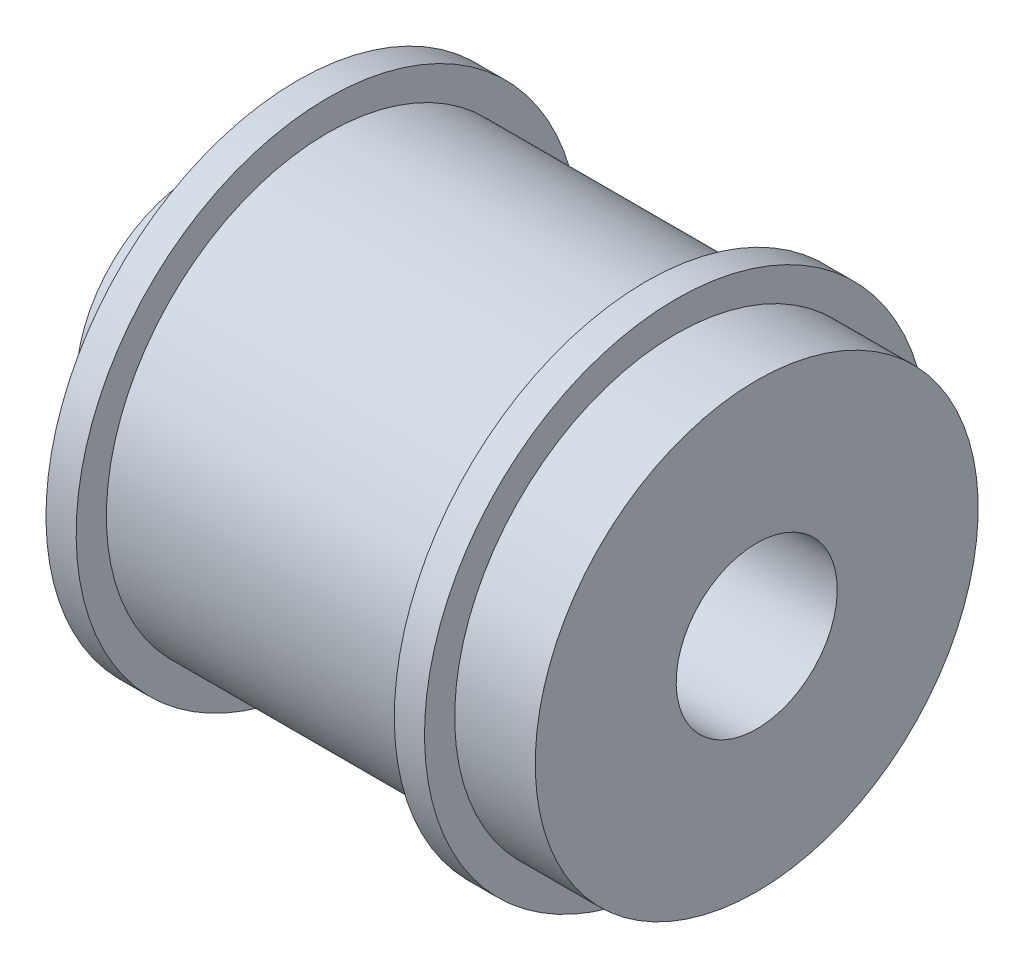
from build123d import *


with BuildPart() as part:
    # Sketch1 → Revolve1 (revolve)
    with BuildSketch(Plane.XY):
        Polygon((0, 11), (-4, 11), (-4, 12.5), (-5.5, 12.5), (-5.5, 11), (-21.3, 11), (-21.3, 12.5), (-22.8, 12.5), (-22.8, 6), (-27.8, 6), (-27.8, 0), (-9.773646073, 0), (-9.773646073, 4), (0, 4), align=None)
    revolve(axis=Axis((-9.773646073, 0, 0), (-1, 0, 0)))


solid = part.part
